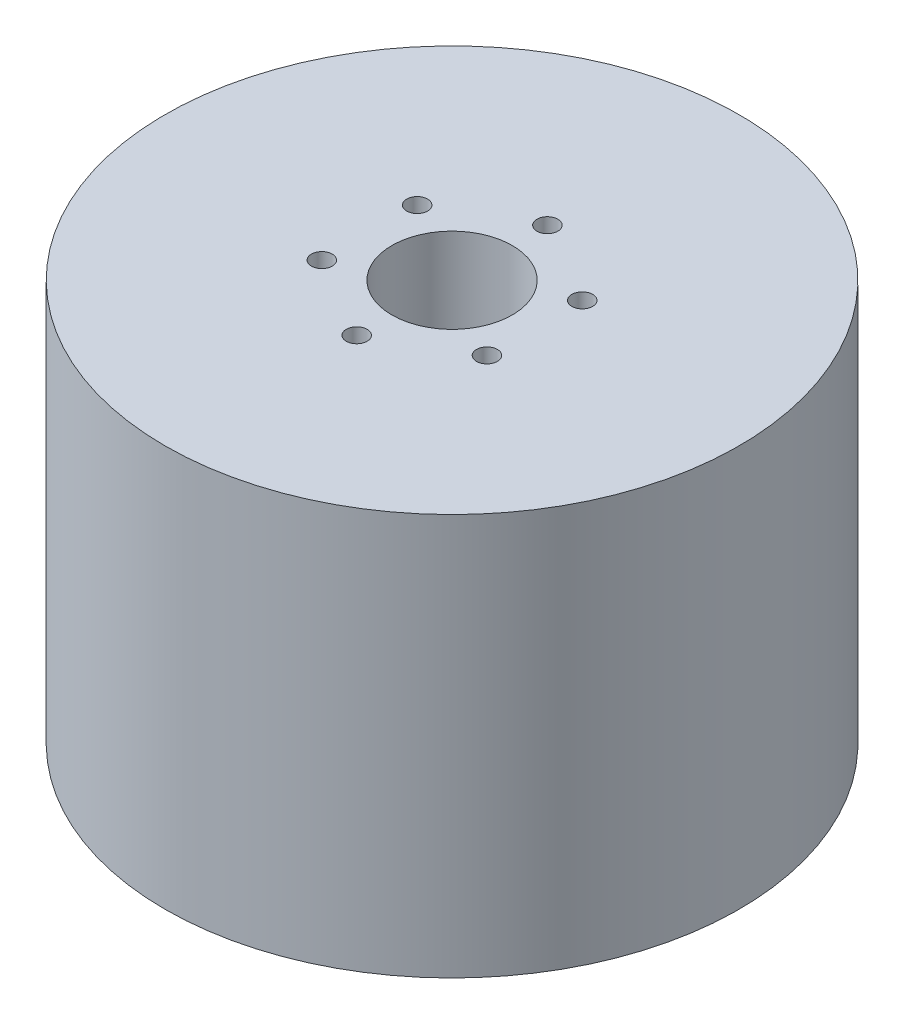
from build123d import *

# Parameters (mm, degrees)
SKETCH1_R           = 71.5
SKETCH1_R_2         = 15
SKETCH1_R_3         = 2.6
BOSS_EXTRUDE1_DEPTH = 100


with BuildPart() as part:
    # Sketch1 → Boss-Extrude1 (new body)
    with BuildSketch(Plane(origin=(0, 0, 0), x_dir=(1, 0, 0), z_dir=(0, 1, 0))):
        Circle(SKETCH1_R)
        Circle(SKETCH1_R_2, mode=Mode.SUBTRACT)
        with Locations((0, 23.75)):
            Circle(SKETCH1_R_3, mode=Mode.SUBTRACT)
        with Locations((20.56810334, 11.875)):
            Circle(SKETCH1_R_3, mode=Mode.SUBTRACT)
        with Locations((20.56810334, -11.875)):
            Circle(SKETCH1_R_3, mode=Mode.SUBTRACT)
        with Locations((0, -23.75)):
            Circle(SKETCH1_R_3, mode=Mode.SUBTRACT)
        with Locations((-20.56810334, -11.875)):
            Circle(SKETCH1_R_3, mode=Mode.SUBTRACT)
        with Locations((-20.56810334, 11.875)):
            Circle(SKETCH1_R_3, mode=Mode.SUBTRACT)
    extrude(amount=BOSS_EXTRUDE1_DEPTH)


solid = part.part
